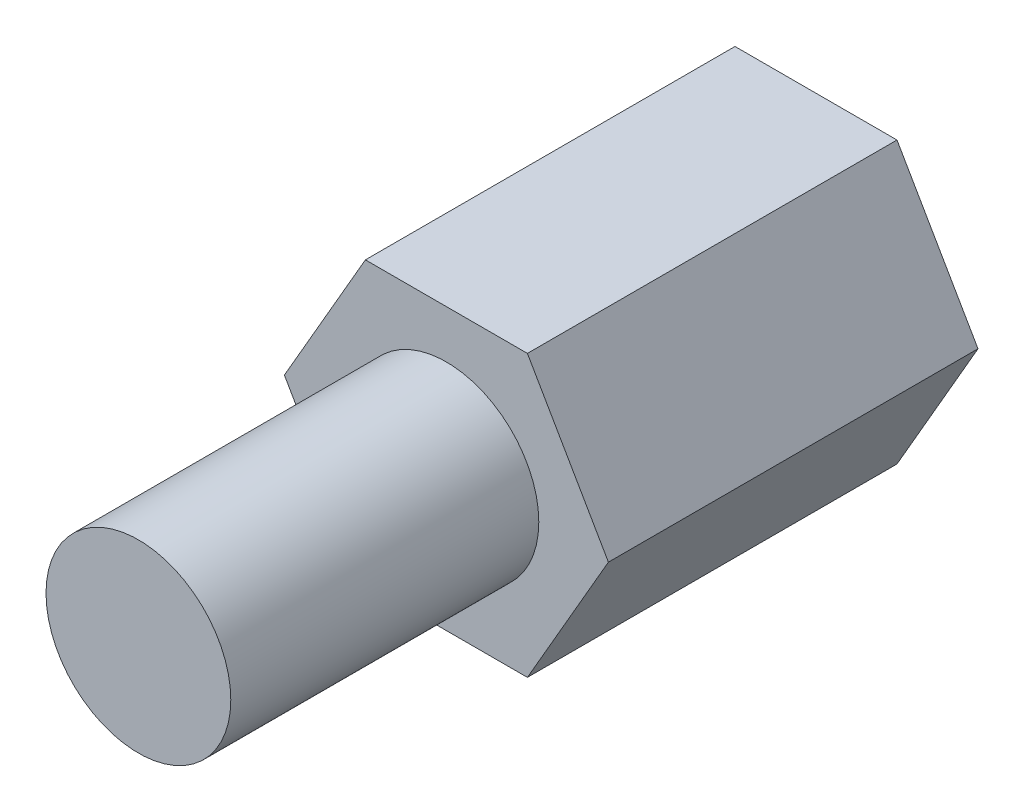
from build123d import *

# Parameters (mm, degrees)
EXTRUDE_1_DEPTH = 6
M3X0_5_1_D      = 2.5
M3X0_5_1_DEPTH  = 4
M3X0_5_1_TIP    = 0.751075774
SKETCH_5_R      = 1.5
EXTRUDE_2_DEPTH = 5


with BuildPart() as part:
    # 草圖1 → 填料-伸長1 (new body)
    with BuildSketch(Plane.XY):
        Polygon((2.63, 0), (1.315, 2.277646812), (-1.315, 2.277646812), (-2.63, 0), (-1.315, -2.277646812), (1.315, -2.277646812), align=None)
    extrude(amount=EXTRUDE_1_DEPTH)

    # M3x0.5 螺紋孔1
    with Locations(Plane(origin=(0, 0, 0), x_dir=(-1, 0, 0), z_dir=(0, 0, -1))):
        with Locations((0, 0)):
            Hole(M3X0_5_1_D / 2, depth=M3X0_5_1_DEPTH)
            with Locations((0, 0, -(M3X0_5_1_DEPTH + M3X0_5_1_TIP / 2))):  # 118° drill point
                Cone(0, M3X0_5_1_D / 2, M3X0_5_1_TIP, mode=Mode.SUBTRACT)

    # 草圖5 → 填料-伸長2 (add)
    with BuildSketch(Plane.XY.offset(6)):
        Circle(SKETCH_5_R)
    extrude(amount=EXTRUDE_2_DEPTH)


solid = part.part
